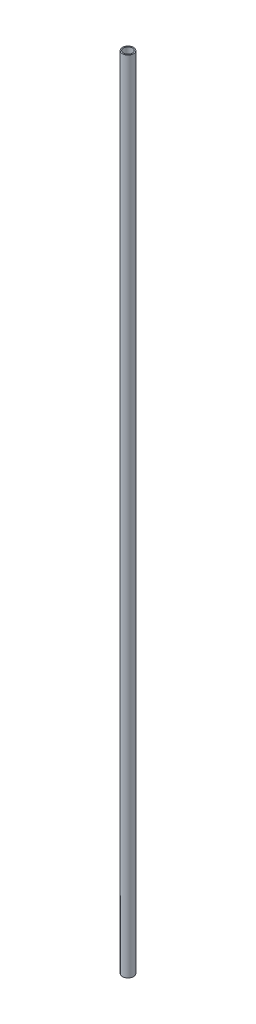
from build123d import *

# Parameters (mm, degrees)
BOSS_EXTRUDE1_DEPTH      = 457.2
BOSS_EXTRUDE1_DEPTH_BACK = 457.2
SKETCH1_R                = 6.35
SKETCH1_R_2              = 5.08


with BuildPart() as part:
    # Sketch1 → Boss-Extrude1 (new, two sides: drawn at the far end of the back side and taken through both)
    with BuildSketch(Plane(origin=(0, 0, 0), x_dir=(1, 0, 0), z_dir=(0, 1, 0)).offset(-BOSS_EXTRUDE1_DEPTH_BACK)):
        Circle(SKETCH1_R)
        Circle(SKETCH1_R_2, mode=Mode.SUBTRACT)
    extrude(amount=BOSS_EXTRUDE1_DEPTH + BOSS_EXTRUDE1_DEPTH_BACK)


solid = part.part
